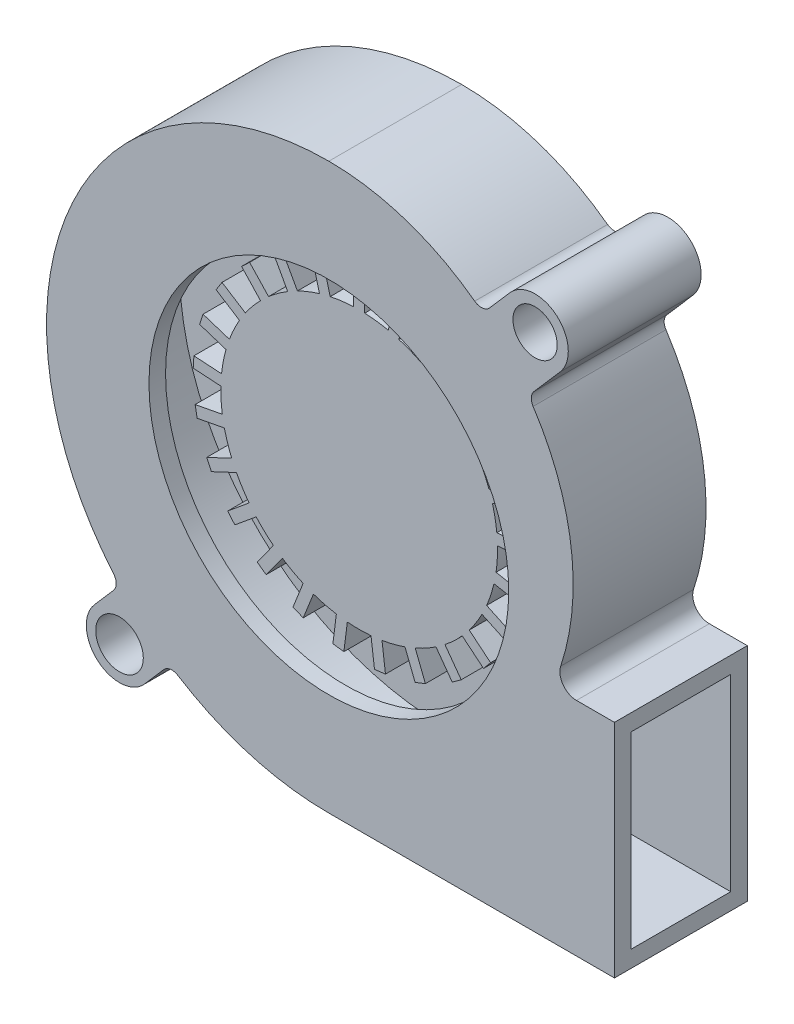
from build123d import *

# Parameters (mm, degrees)
BOSS_EXTRUDE1_DEPTH = 12
CUT_EXTRUDE2_DEPTH  = 28.5
SHELL1_T            = -1.5
SKETCH2_R           = 16.25
CUT_EXTRUDE1_DEPTH  = 3.76
SKETCH3_R           = 12.5
BOSS_EXTRUDE2_DEPTH = 7.76
BOSS_EXTRUDE3_DEPTH = 7.76
CIRPATTERN1_COUNT   = 25
FILLET1_R           = 1.5
SKETCH6_R           = 2.15
BOSS_EXTRUDE4_DEPTH = 12
FILLET2_R           = 1
SKETCH7_R           = 2
BOSS_EXTRUDE5_DEPTH = 12
FILLET3_R           = 1


with BuildPart() as part:
    # Sketch1 → Boss-Extrude1 (new body)
    with BuildSketch(Plane.XY):
        with BuildLine():
            Line((0, -25.5), (25.8, -25.5))
            Line((25.8, -25.5), (25.8, -5.5))
            Line((25.8, -5.5), (24.899799196, -5.5))
            ThreePointArc((24.899799196, -5.5), (-15.968719423, 19.880895352), (0, -25.5))
        make_face()
    extrude(amount=BOSS_EXTRUDE1_DEPTH)

    # Sketch5 → Cut-Extrude2 (cut)
    with BuildSketch(Plane.XY.offset(12)):
        with BuildLine():
            Line((24.899799196, -5.5), (20.18266583, -5.5))
            ThreePointArc((20.18266583, -5.5), (18.495540003, 15.471590427), (0, 25.5))
            ThreePointArc((0, 25.5), (19.880895352, 15.968719423), (24.899799196, -5.5))
        make_face()
    extrude(amount=-CUT_EXTRUDE2_DEPTH, mode=Mode.SUBTRACT)

    # Shell1
    shell1_openings = [part.faces().sort_by_distance(p)[0] for p in [
        (25.8, -15.5, 6),
    ]]
    offset(amount=SHELL1_T, openings=shell1_openings, kind=Kind.INTERSECTION)

    # Sketch2 → Cut-Extrude1 (cut)
    with BuildSketch(Plane.XY.offset(12)):
        Circle(SKETCH2_R)
    extrude(amount=-CUT_EXTRUDE1_DEPTH, mode=Mode.SUBTRACT)

    # Sketch3 → Boss-Extrude2 (add)
    with BuildSketch(Plane.XY.offset(1.5)):
        Circle(SKETCH3_R)
    extrude(amount=BOSS_EXTRUDE2_DEPTH)

    # Sketch4 → Boss-Extrude3 (add)
    with BuildSketch(Plane.XY.offset(1.5)):
        with BuildLine():
            Line((-0.5, 12.489995997), (-0.5, 14.989995997))
            Line((-0.5, 14.989995997), (0.5, 14.989995997))
            Line((0.5, 14.989995997), (0.5, 12.489995997))
            ThreePointArc((0.5, 12.489995997), (0, 12.5), (-0.5, 12.489995997))
        make_face()
    boss_extrude3 = extrude(amount=BOSS_EXTRUDE3_DEPTH)

    # CirPattern1: Boss-Extrude3 ×25 about axis
    cirpattern1_axis = Axis((0, 0, 0), (0, 0, 1))
    for i in range(1, CIRPATTERN1_COUNT):
        add(boss_extrude3.rotate(cirpattern1_axis, i * 360 / CIRPATTERN1_COUNT))

    # Fillet1
    fillet1_edges = [part.edges().sort_by_distance(p)[0] for p in [
        (20.18266583, -5.5, 6),
    ]]
    fillet(fillet1_edges, radius=FILLET1_R)

    # Sketch6 → Boss-Extrude4 (add)
    with BuildSketch(Plane.XY.offset(12)):
        with BuildLine():
            Line((-18.877455455, -17.143269104), (-21.173662056, -19.784752634))
            ThreePointArc((-21.173662056, -19.784752634), (-20.877710402, -24.017058462), (-16.645404575, -23.721106808))
            Line((-16.645404575, -23.721106808), (-14.349197973, -21.079623278))
            ThreePointArc((-14.349197973, -21.079623278), (-16.729505239, -19.245094296), (-18.877455455, -17.143269104))
        make_face()
        with Locations((-18.909533315, -21.752929721)):
            Circle(SKETCH6_R, mode=Mode.SUBTRACT)
    extrude(amount=-BOSS_EXTRUDE4_DEPTH)

    # Fillet2
    fillet2_edges = [part.edges().sort_by_distance(p)[0] for p in [
        (-14.349197973, -21.079623278, 6),
        (-18.877455455, -17.143269104, 6),
    ]]
    fillet(fillet2_edges, radius=FILLET2_R)

    # Sketch7 → Boss-Extrude5 (add)
    with BuildSketch(Plane.XY.offset(12)):
        with BuildLine():
            Line((13.905047135, 20.568686185), (16.365268494, 23.398847111))
            ThreePointArc((16.365268494, 23.398847111), (20.597574322, 23.694798765), (20.893525975, 19.462492937))
            Line((20.893525975, 19.462492937), (18.02598514, 16.163764554))
            ThreePointArc((18.02598514, 16.163764554), (16.116716142, 18.507677567), (13.905047135, 20.568686185))
        make_face()
        with Locations((18.629397235, 21.430670024)):
            Circle(SKETCH7_R, mode=Mode.SUBTRACT)
    extrude(amount=-BOSS_EXTRUDE5_DEPTH)

    # Fillet3
    fillet3_edges = [part.edges().sort_by_distance(p)[0] for p in [
        (13.905047135, 20.568686185, 6),
        (18.02598514, 16.163764554, 6),
    ]]
    fillet(fillet3_edges, radius=FILLET3_R)


solid = part.part
